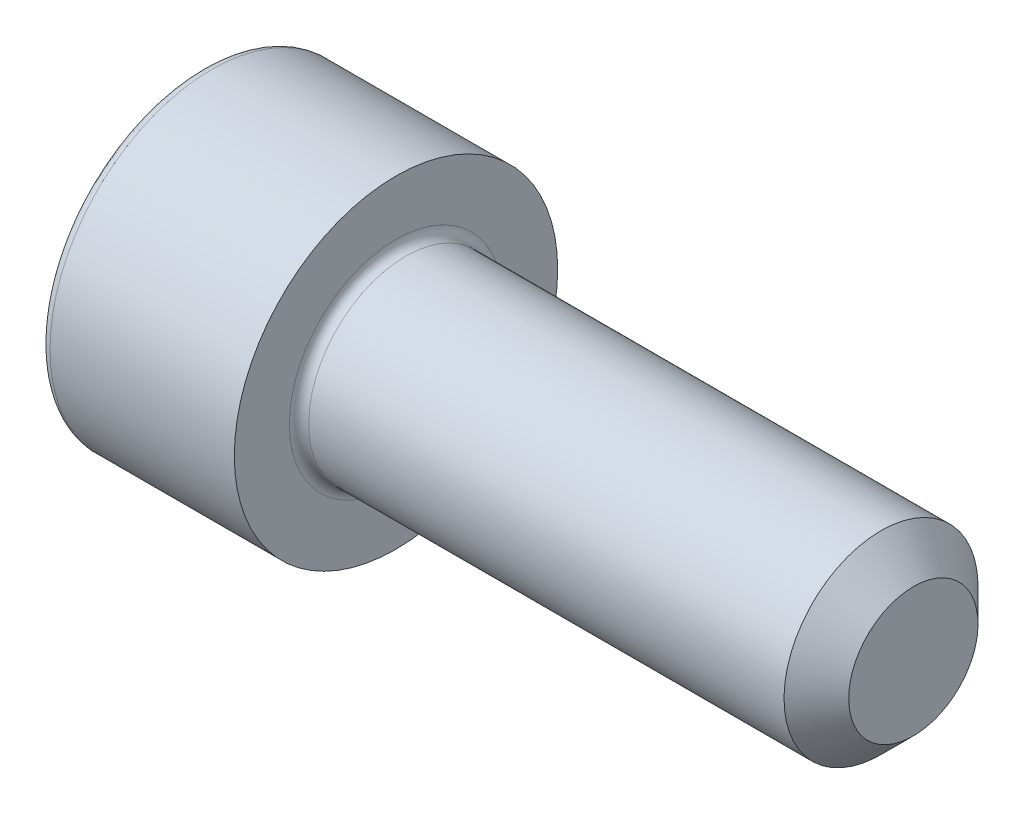
from build123d import *

# Parameters (mm, degrees)
CUT_EXTRUDE_1_DEPTH = 2.5
FILLET_1_R          = 0.3
CHAMFER_1_SIZE      = 1


with BuildPart() as part:
    # Эскиз1 → Повернуть1 (revolve)
    with BuildSketch(Plane.XY):
        Polygon((0, 0), (0, 5), (6, 5), (6, 3), (22, 3), (22, 0), align=None)
    revolve(axis=Axis((22, 0, 0), (-1, 0, 0)))

    # Эскиз2 → Вырез-Вытянуть1 (cut)
    with BuildSketch(Plane.ZY):
        Polygon((-1.443375673, 2.5), (-2.886751346, 0), (-1.443375673, -2.5), (1.443375673, -2.5), (2.886751346, 0), (1.443375673, 2.5), align=None)
    extrude(amount=-CUT_EXTRUDE_1_DEPTH, mode=Mode.SUBTRACT)

    # Скругление1
    fillet_1_edges = [part.edges().sort_by_distance(p)[0] for p in [
        (6, -3, 0),
        (0, -5, 0),
    ]]
    fillet(fillet_1_edges, radius=FILLET_1_R)

    # Фаска1
    chamfer_1_edges = [part.edges().sort_by_distance(p)[0] for p in [
        (22, -3, 0),
    ]]
    chamfer(chamfer_1_edges, length=CHAMFER_1_SIZE)


solid = part.part
